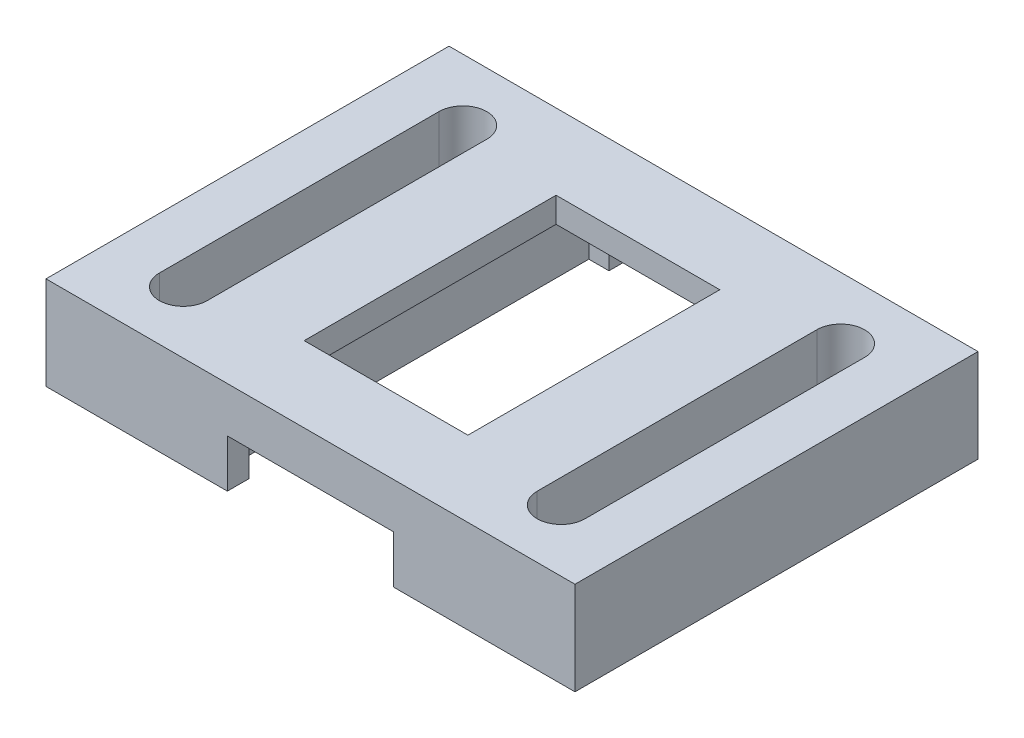
from build123d import *

# Parameters (mm, degrees)
SKETCH1_W           = 10
SKETCH1_H           = 16
BOSS_EXTRUDE1_DEPTH = 3.7
SKETCH2_W           = 8.2
SKETCH2_H           = 14.3
CUT_EXTRUDE1_DEPTH  = 2.7
SKETCH3_W           = 6.6
SKETCH3_H           = 16
CUT_EXTRUDE2_DEPTH  = 1.9
CUT_EXTRUDE3_REACH  = 5.7
SKETCH4_W           = 6.5
SKETCH4_H           = 10
SKETCH5_W           = 5.5
SKETCH5_H           = 16
BOSS_EXTRUDE2_DEPTH = 3.7
CUT_EXTRUDE4_DEPTH  = 4.7


with BuildPart() as part:
    # Sketch1 → Boss-Extrude1 (new body)
    with BuildSketch(Plane(origin=(0, 0, 0), x_dir=(1, 0, 0), z_dir=(0, 1, 0))):
        Rectangle(SKETCH1_W, SKETCH1_H)
    extrude(amount=BOSS_EXTRUDE1_DEPTH)

    # Sketch2 → Cut-Extrude1 (cut)
    with BuildSketch(Plane.XZ):
        Rectangle(SKETCH2_W, SKETCH2_H)
    extrude(amount=-CUT_EXTRUDE1_DEPTH, mode=Mode.SUBTRACT)

    # Sketch3 → Cut-Extrude2 (cut)
    with BuildSketch(Plane.XZ):
        Rectangle(SKETCH3_W, SKETCH3_H)
    extrude(amount=-CUT_EXTRUDE2_DEPTH, mode=Mode.SUBTRACT)

    # Sketch4 → Cut-Extrude3 (cut, up to next)
    with BuildSketch(Plane(origin=(0, 3.7, 0), x_dir=(1, 0, 0), z_dir=(0, 1, 0)), mode=Mode.PRIVATE) as cut_extrude3_sk1:
        Rectangle(SKETCH4_W, SKETCH4_H)
    cut_extrude3_tool1 = extrude(cut_extrude3_sk1.sketch, amount=-CUT_EXTRUDE3_REACH, mode=Mode.PRIVATE) & part.part
    add(cut_extrude3_tool1.solids().sort_by_distance((0, 3.7, 0))[0], mode=Mode.SUBTRACT)

    # Sketch5 → Boss-Extrude2 (add)
    with BuildSketch(Plane.XZ):
        with Locations((-7.75, 0)):
            Rectangle(SKETCH5_W, SKETCH5_H)
    boss_extrude2 = extrude(amount=-BOSS_EXTRUDE2_DEPTH)

    # Sketch6 → Cut-Extrude4 (cut, through all)
    with BuildSketch(Plane(origin=(0, 3.7, 0), x_dir=(1, 0, 0), z_dir=(0, 1, 0))):
        with BuildLine():
            Line((-6.55, 5.55), (-6.55, -5.55))
            ThreePointArc((-6.55, -5.55), (-7.5, -6.5), (-8.45, -5.55))
            Line((-8.45, -5.55), (-8.45, 5.55))
            ThreePointArc((-8.45, 5.55), (-7.5, 6.5), (-6.55, 5.55))
        make_face()
    cut_extrude4 = extrude(amount=-CUT_EXTRUDE4_DEPTH, mode=Mode.SUBTRACT)

    # Mirror1: Boss-Extrude2, Cut-Extrude4 across plane
    add(boss_extrude2.mirror(Plane(origin=(0, 0, 0), x_dir=(0, 0, 1), z_dir=(1, 0, 0))))
    add(cut_extrude4.mirror(Plane(origin=(0, 0, 0), x_dir=(0, 0, 1), z_dir=(1, 0, 0))), mode=Mode.SUBTRACT)


solid = part.part
